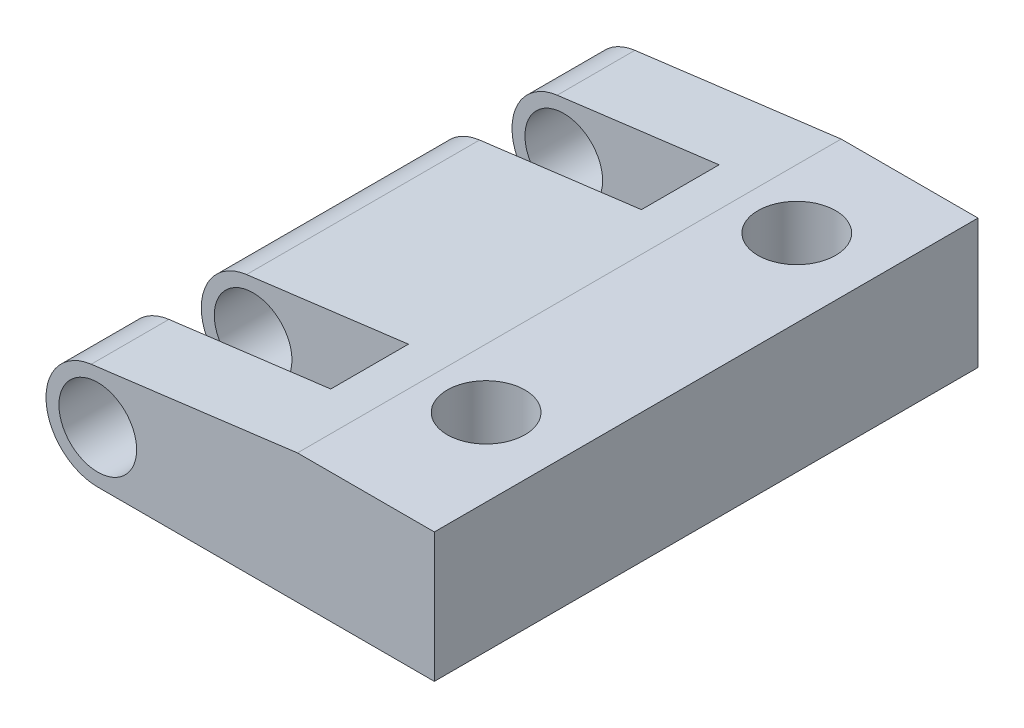
from build123d import *

# Parameters (mm, degrees)
SKETCH_1_R          = 1.5
EXTRUDE_1_DEPTH     = 21
SKETCH_3_W          = 8
SKETCH_3_H          = 3
CUT_EXTRUDE_1_DEPTH = 6
SKETCH_4_R          = 1.5
CUT_EXTRUDE_2_DEPTH = 21


with BuildPart() as part:
    # 草图1 → 凸台-拉伸1 (new body)
    with BuildSketch(Plane.XY):
        with BuildLine():
            Line((-1.936190112, 5), (3.350194549, 5))
            Line((3.350194549, 5), (3.350194549, 0))
            Line((3.350194549, 0), (0, 0))
            Line((0, 0), (-9.649805451, 0))
            ThreePointArc((-9.649805451, 0), (-11.645783707, 1.873229335), (-9.902836943, 3.983929198))
            Line((-9.902836943, 3.983929198), (-1.936190112, 5))
        make_face()
        with Locations((-9.649805451, 2)):
            Circle(SKETCH_1_R, mode=Mode.SUBTRACT)
    extrude(amount=EXTRUDE_1_DEPTH)

    # 草图3 → 切除-拉伸1 (cut, through all)
    with BuildSketch(Plane(origin=(0, 0, 0), x_dir=(1, 0, 0), z_dir=(0, 1, 0))):
        with Locations((-7.649805451, -4.5)):
            Rectangle(SKETCH_3_W, SKETCH_3_H)
        with Locations((-7.649805451, -16.5)):
            Rectangle(SKETCH_3_W, SKETCH_3_H)
    extrude(amount=CUT_EXTRUDE_1_DEPTH, mode=Mode.SUBTRACT)

    # 草图4 → 切除-拉伸2 (cut)
    with BuildSketch(Plane(origin=(0, 5, 0), x_dir=(1, 0, 0), z_dir=(0, 1, 0))):
        with Locations((0.350194549, -4)):
            Circle(SKETCH_4_R)
        with Locations((0.350194549, -16)):
            Circle(SKETCH_4_R)
    extrude(amount=-CUT_EXTRUDE_2_DEPTH, mode=Mode.SUBTRACT)


solid = part.part
